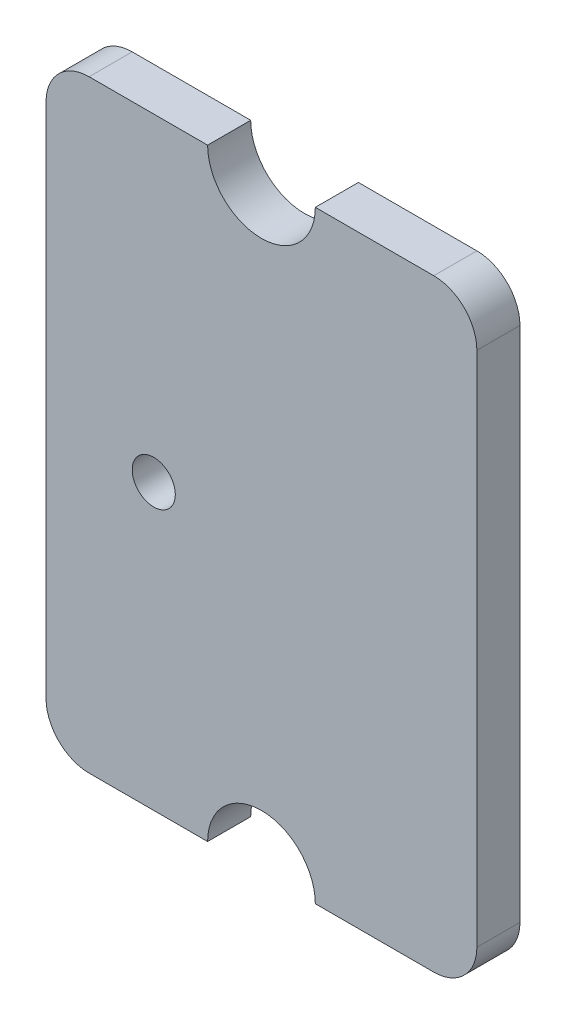
from build123d import *

# Parameters (mm, degrees)
ESQUISSE1_R        = 0.5
BOSS_EXTRU_1_DEPTH = 1


with BuildPart() as part:
    # Esquisse1 → Boss.-Extru.1 (new body)
    with BuildSketch(Plane.XY):
        with BuildLine():
            Line((1.25, 7), (4, 7))
            ThreePointArc((4, 7), (4.707106781, 6.707106781), (5, 6))
            Line((5, 6), (5, -6))
            ThreePointArc((5, -6), (4.707106781, -6.707106781), (4, -7))
            Line((4, -7), (1.25, -7))
            ThreePointArc((1.25, -7), (0, -5.75), (-1.25, -7))
            Line((-1.25, -7), (-4, -7))
            ThreePointArc((-4, -7), (-4.707106781, -6.707106781), (-5, -6))
            Line((-5, -6), (-5, 6))
            ThreePointArc((-5, 6), (-4.707106781, 6.707106781), (-4, 7))
            Line((-4, 7), (-1.25, 7))
            ThreePointArc((-1.25, 7), (0, 5.75), (1.25, 7))
        make_face()
        with Locations((-2.5, -0.4)):
            Circle(ESQUISSE1_R, mode=Mode.SUBTRACT)
    extrude(amount=BOSS_EXTRU_1_DEPTH)


solid = part.part
